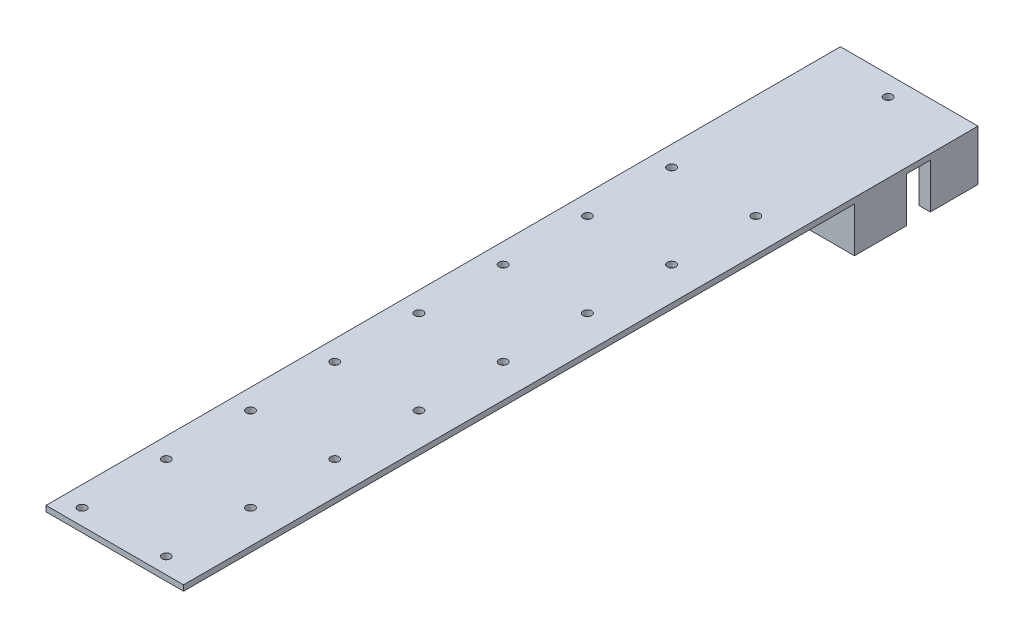
from build123d import *

# Parameters (mm, degrees)
ESQUISSE1_W             = 49
ESQUISSE1_H             = 283
ESQUISSE1_R             = 1.5
BOSS_EXTRU_1_DEPTH      = 2
ESQUISSE2_W             = 42.8
ESQUISSE2_H             = 18.6
ESQUISSE2_W_2           = 4
ESQUISSE2_H_2           = 17
BOSS_EXTRU_2_DEPTH      = 16
ESQUISSE3_R             = 1.5
ENL_V_MAT_EXTRU_1_DEPTH = 16


with BuildPart() as part:
    # Esquisse1 → Boss.-Extru.1 (new body)
    with BuildSketch(Plane(origin=(0, 0, 0), x_dir=(1, 0, 0), z_dir=(0, 1, 0))):
        Rectangle(ESQUISSE1_W, ESQUISSE1_H)
        with Locations((12.65, 74.2)):
            Circle(ESQUISSE1_R, mode=Mode.SUBTRACT)
        with Locations((-17.35, 74.2)):
            Circle(ESQUISSE1_R, mode=Mode.SUBTRACT)
        with Locations((-17.35, 44.2)):
            Circle(ESQUISSE1_R, mode=Mode.SUBTRACT)
        with Locations((-17.35, 14.2)):
            Circle(ESQUISSE1_R, mode=Mode.SUBTRACT)
        with Locations((-17.35, -15.8)):
            Circle(ESQUISSE1_R, mode=Mode.SUBTRACT)
        with Locations((-17.35, -45.8)):
            Circle(ESQUISSE1_R, mode=Mode.SUBTRACT)
        with Locations((-17.35, -75.8)):
            Circle(ESQUISSE1_R, mode=Mode.SUBTRACT)
        with Locations((-17.35, -105.8)):
            Circle(ESQUISSE1_R, mode=Mode.SUBTRACT)
        with Locations((-17.35, -135.8)):
            Circle(ESQUISSE1_R, mode=Mode.SUBTRACT)
        with Locations((12.65, 44.2)):
            Circle(ESQUISSE1_R, mode=Mode.SUBTRACT)
        with Locations((12.65, 14.2)):
            Circle(ESQUISSE1_R, mode=Mode.SUBTRACT)
        with Locations((12.65, -15.8)):
            Circle(ESQUISSE1_R, mode=Mode.SUBTRACT)
        with Locations((12.65, -45.8)):
            Circle(ESQUISSE1_R, mode=Mode.SUBTRACT)
        with Locations((12.65, -75.8)):
            Circle(ESQUISSE1_R, mode=Mode.SUBTRACT)
        with Locations((12.65, -105.8)):
            Circle(ESQUISSE1_R, mode=Mode.SUBTRACT)
        with Locations((12.65, -135.8)):
            Circle(ESQUISSE1_R, mode=Mode.SUBTRACT)
    extrude(amount=BOSS_EXTRU_1_DEPTH)

    # Esquisse2 → Boss.-Extru.2 (add)
    with BuildSketch(Plane.XZ):
        with Locations((3.1, -106.8)):
            Rectangle(ESQUISSE2_W, ESQUISSE2_H)
        with Locations((-21.1, -133)):
            Rectangle(ESQUISSE2_W_2, ESQUISSE2_H_2)
        with Locations((22.5, -133)):
            Rectangle(ESQUISSE2_W_2, ESQUISSE2_H_2)
    extrude(amount=BOSS_EXTRU_2_DEPTH)

    # Esquisse3 → Enlèv. mat.-Extru.1 (cut)
    with BuildSketch(Plane.XZ):
        with Locations((-0.5, -134.5)):
            Circle(ESQUISSE3_R)
    extrude(amount=-ENL_V_MAT_EXTRU_1_DEPTH, mode=Mode.SUBTRACT)


solid = part.part
